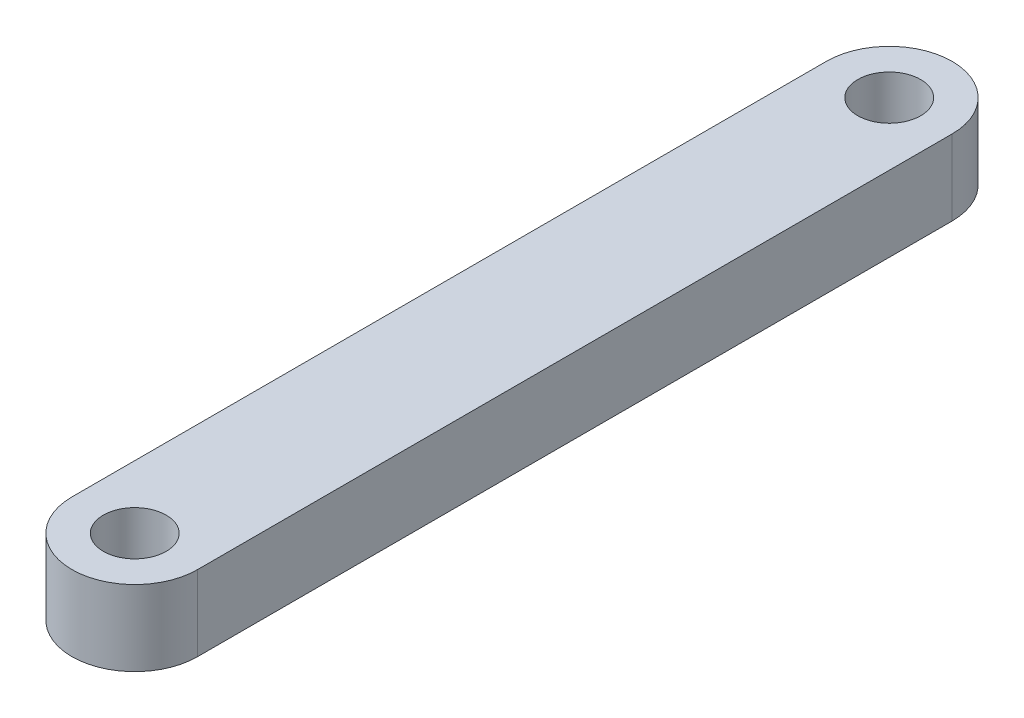
from build123d import *

# Parameters (mm, degrees)
SKETCH1_R           = 1
BOSS_EXTRUDE1_DEPTH = 3
SKETCH2_R           = 1.25
CUT_EXTRUDE1_DEPTH  = 4
SKETCH3_R           = 1.25
CUT_EXTRUDE2_DEPTH  = 4


with BuildPart() as part:
    # Sketch1 → Boss-Extrude1 (new body)
    with BuildSketch(Plane(origin=(0, 2.5, 0), x_dir=(1, 0, 0), z_dir=(0, 1, 0))):
        with BuildLine():
            Line((-2.5, -48.662329453), (-2.5, -18.662329453))
            ThreePointArc((-2.5, -18.662329453), (-5, -16.162329453), (-7.5, -18.662329453))
            Line((-7.5, -18.662329453), (-7.5, -48.662329453))
            ThreePointArc((-7.5, -48.662329453), (-5, -51.162329453), (-2.5, -48.662329453))
        make_face()
        with Locations((-5, -48.662329453)):
            Circle(SKETCH1_R, mode=Mode.SUBTRACT)
        with Locations((-5, -18.662329453)):
            Circle(SKETCH1_R, mode=Mode.SUBTRACT)
    extrude(amount=-BOSS_EXTRUDE1_DEPTH)

    # Sketch2 → Cut-Extrude1 (cut, through all)
    with BuildSketch(Plane.XZ.offset(0.5)):
        with Locations((-5, 18.662329453)):
            Circle(SKETCH2_R)
    extrude(amount=-CUT_EXTRUDE1_DEPTH, mode=Mode.SUBTRACT)

    # Sketch3 → Cut-Extrude2 (cut, through all)
    with BuildSketch(Plane.XZ.offset(0.5)):
        with Locations((-5, 48.662329453)):
            Circle(SKETCH3_R)
    extrude(amount=-CUT_EXTRUDE2_DEPTH, mode=Mode.SUBTRACT)


solid = part.part
